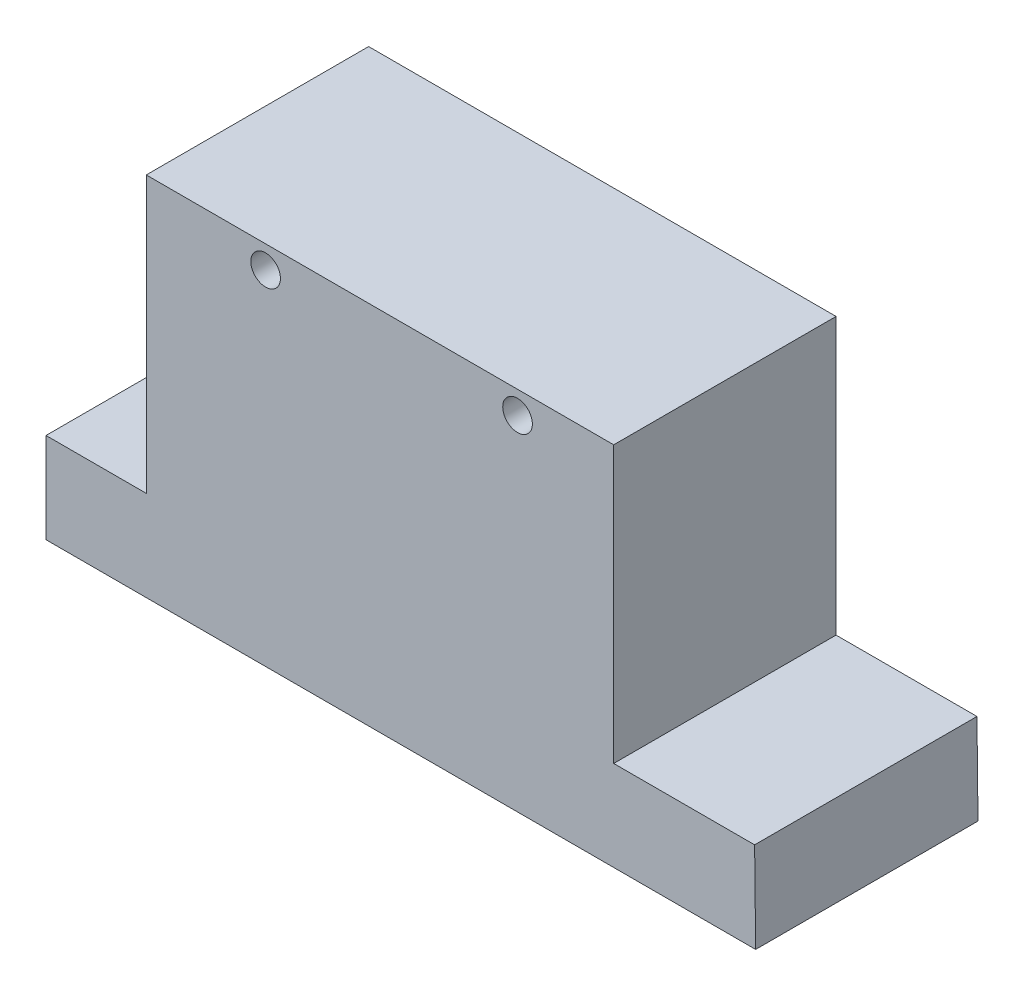
from build123d import *

# Parameters (mm, degrees)
SKETCH1_R           = 4
BOSS_EXTRUDE1_DEPTH = 60


with BuildPart() as part:
    # Sketch1 → Boss-Extrude1 (new body)
    with BuildSketch(Plane.XY):
        Polygon((-78.477343622, -6.715827259), (-105.53442836, -6.715827259), (-105.53442836, -31.084686171), (-55.837306641, -31.084686171), (31.27656695, -31.084686171), (85.964626644, -31.084686171), (85.685037395, -6.772556192), (47.660564626, -6.772556192), (47.660564626, 67.701117608), (-78.477343622, 67.701117608), align=None)
        with Locations((-46.271365908, 61.586520729)):
            Circle(SKETCH1_R, mode=Mode.SUBTRACT)
        with Locations((21.710626217, 61.586520729)):
            Circle(SKETCH1_R, mode=Mode.SUBTRACT)
    extrude(amount=BOSS_EXTRUDE1_DEPTH)


solid = part.part
